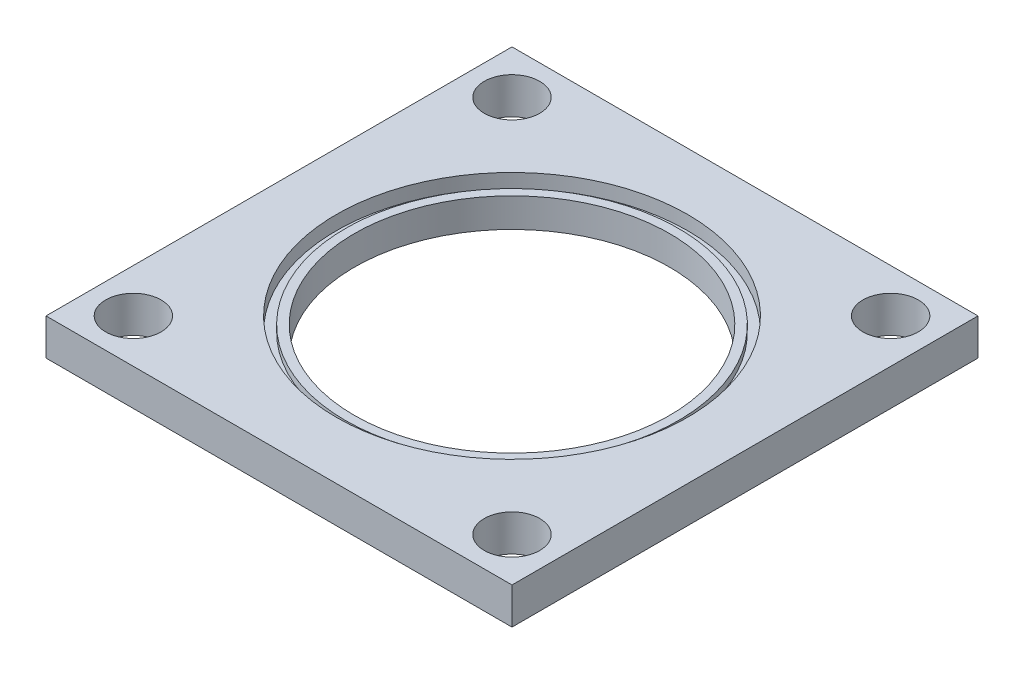
from build123d import *

# Parameters (mm, degrees)
PLATEOUTLINE_W      = 80
PLATEOUTLINE_H      = 80
BOSS_EXTRUDE1_DEPTH = 6.2738
RAILGUIDES_R        = 4.7625
CUT_EXTRUDE1_DEPTH  = 10
CUT_EXTRUDE2_START  = 5
FUELGRAINMOUNTING_R = 30.1625
CUT_EXTRUDE2_DEPTH  = 5
GASINTAKE_R         = 27.051
CUT_EXTRUDE3_DEPTH  = 5
CUT_EXTRUDE4_START  = 5
SKETCH1_R           = 30.1625
SKETCH1_R_2         = 28.575
CUT_EXTRUDE4_DEPTH  = 1.143


with BuildPart() as part:
    # plateOutline → Boss-Extrude1 (new body)
    with BuildSketch(Plane(origin=(0, 0, 0), x_dir=(1, 0, 0), z_dir=(0, 1, 0))):
        Rectangle(PLATEOUTLINE_W, PLATEOUTLINE_H)
    extrude(amount=BOSS_EXTRUDE1_DEPTH)

    # railGuides → Cut-Extrude1 (cut)
    with BuildSketch(Plane(origin=(0, 0, 0), x_dir=(1, 0, 0), z_dir=(0, 1, 0))):
        with Locations((-32.5, 32.5)):
            Circle(RAILGUIDES_R)
        with Locations((32.5, 32.5)):
            Circle(RAILGUIDES_R)
        with Locations((32.5, -32.5)):
            Circle(RAILGUIDES_R)
        with Locations((-32.5, -32.5)):
            Circle(RAILGUIDES_R)
    extrude(amount=CUT_EXTRUDE1_DEPTH, mode=Mode.SUBTRACT)

    # FuelGrainMounting → Cut-Extrude2 (cut)
    with BuildSketch(Plane(origin=(0, 0, 0), x_dir=(1, 0, 0), z_dir=(0, 1, 0)).offset(CUT_EXTRUDE2_START)):
        Circle(FUELGRAINMOUNTING_R)
    extrude(amount=CUT_EXTRUDE2_DEPTH, mode=Mode.SUBTRACT)

    # GasIntake → Cut-Extrude3 (cut)
    with BuildSketch(Plane(origin=(0, 0, 0), x_dir=(1, 0, 0), z_dir=(0, 1, 0))):
        Circle(GASINTAKE_R)
    extrude(amount=CUT_EXTRUDE3_DEPTH, mode=Mode.SUBTRACT)

    # Sketch1 → Cut-Extrude4 (cut)
    with BuildSketch(Plane(origin=(0, 0, 0), x_dir=(1, 0, 0), z_dir=(0, 1, 0)).offset(CUT_EXTRUDE4_START)):
        Circle(SKETCH1_R)
        Circle(SKETCH1_R_2, mode=Mode.SUBTRACT)
    extrude(amount=-CUT_EXTRUDE4_DEPTH, mode=Mode.SUBTRACT)


solid = part.part
